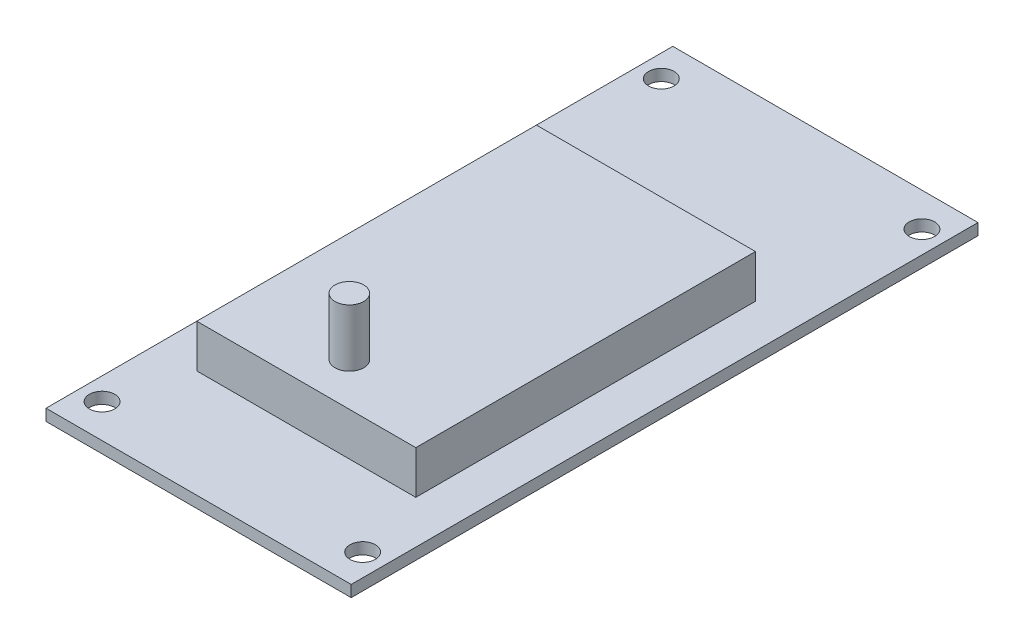
from build123d import *

# Parameters (mm, degrees)
SKETCH1_W           = 42.51
SKETCH1_H           = 87.31
SKETCH1_R           = 1.77
BOSS_EXTRUDE1_DEPTH = 1.6
SKETCH2_W           = 30.51
SKETCH2_H           = 47.31
BOSS_EXTRUDE2_DEPTH = 6
SKETCH4_R           = 2
BOSS_EXTRUDE3_DEPTH = 8


with BuildPart() as part:
    # Sketch1 → Boss-Extrude1 (new body)
    with BuildSketch(Plane(origin=(0, 0, 0), x_dir=(1, 0, 0), z_dir=(0, 1, 0))):
        with Locations((21.255, 43.655)):
            Rectangle(SKETCH1_W, SKETCH1_H)
        with Locations((3.105, 82.605)):
            Circle(SKETCH1_R, mode=Mode.SUBTRACT)
        with Locations((39.405, 82.605)):
            Circle(SKETCH1_R, mode=Mode.SUBTRACT)
        with Locations((3.105, 4.705)):
            Circle(SKETCH1_R, mode=Mode.SUBTRACT)
        with Locations((39.405, 4.705)):
            Circle(SKETCH1_R, mode=Mode.SUBTRACT)
    extrude(amount=BOSS_EXTRUDE1_DEPTH)

    # Sketch2 → Boss-Extrude2 (add)
    with BuildSketch(Plane(origin=(0, 1.6, 0), x_dir=(1, 0, 0), z_dir=(0, 1, 0))):
        with Locations((21.255, 38.655)):
            Rectangle(SKETCH2_W, SKETCH2_H)
    extrude(amount=BOSS_EXTRUDE2_DEPTH)

    # Sketch4 → Boss-Extrude3 (add)
    with BuildSketch(Plane(origin=(0, 7.6, 0), x_dir=(1, 0, 0), z_dir=(0, 1, 0))):
        with Locations((21.255, 21)):
            Circle(SKETCH4_R)
    extrude(amount=BOSS_EXTRUDE3_DEPTH)


solid = part.part
